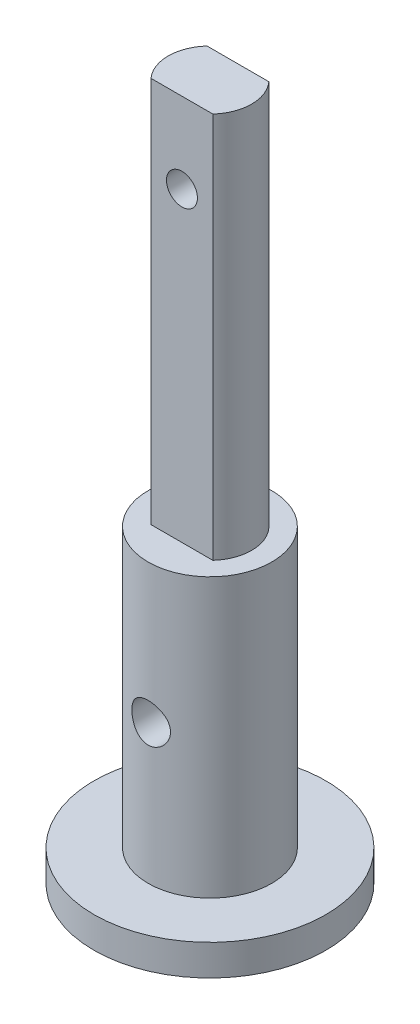
from build123d import *

# Parameters (mm, degrees)
SKETCH1_R               = 7.5
SKETCH1_R_2             = 4
BOSS_EXTRUDE1_DEPTH     = 2
SKETCH1_2_R             = 4
BOSS_EXTRUDE2_DEPTH     = 45
SKETCH2_R               = 4.5
CUT_EXTRUDE1_DEPTH      = 25
CUT_EXTRUDE2_DEPTH      = 25
CUT_EXTRUDE2_DEPTH_BACK = 25
SKETCH3_R               = 1
SKETCH3_R_2             = 1.25


with BuildPart() as part:
    # Sketch1 → Boss-Extrude1 (new body)
    with BuildSketch(Plane(origin=(0, 0, 0), x_dir=(1, 0, 0), z_dir=(0, 1, 0))):
        Circle(SKETCH1_R)
        Circle(SKETCH1_R_2, mode=Mode.SUBTRACT)
    extrude(amount=BOSS_EXTRUDE1_DEPTH)

    # Sketch1_2 → Boss-Extrude2 (add)
    with BuildSketch(Plane(origin=(0, 0, 0), x_dir=(1, 0, 0), z_dir=(0, 1, 0))):
        Circle(SKETCH1_2_R)
    extrude(amount=BOSS_EXTRUDE2_DEPTH)

    # Sketch2 → Cut-Extrude1 (cut)
    with BuildSketch(Plane(origin=(0, 45, 0), x_dir=(1, 0, 0), z_dir=(0, 1, 0))):
        Circle(SKETCH2_R)
        with BuildLine():
            Line((-2, 1.811376185), (2, 1.811376185))
            ThreePointArc((2, 1.811376185), (2.698348325, 0), (2, -1.811376185))
            Line((2, -1.811376185), (-2, -1.811376185))
            ThreePointArc((-2, -1.811376185), (-2.698348325, 0), (-2, 1.811376185))
        make_face(mode=Mode.SUBTRACT)
    extrude(amount=-CUT_EXTRUDE1_DEPTH, mode=Mode.SUBTRACT)

    # Sketch3 → Cut-Extrude2 (cut, two sides: drawn at the far end of the back side and taken through both)
    with BuildSketch(Plane(origin=(0, 0, -1.811376185), x_dir=(-1, 0, 0), z_dir=(0, 0, -1)).offset(-CUT_EXTRUDE2_DEPTH_BACK)):
        with Locations((0, 39.794309812)):
            Circle(SKETCH3_R)
        with Locations((0, 11)):
            Circle(SKETCH3_R_2)
    extrude(amount=CUT_EXTRUDE2_DEPTH + CUT_EXTRUDE2_DEPTH_BACK, mode=Mode.SUBTRACT)


solid = part.part
